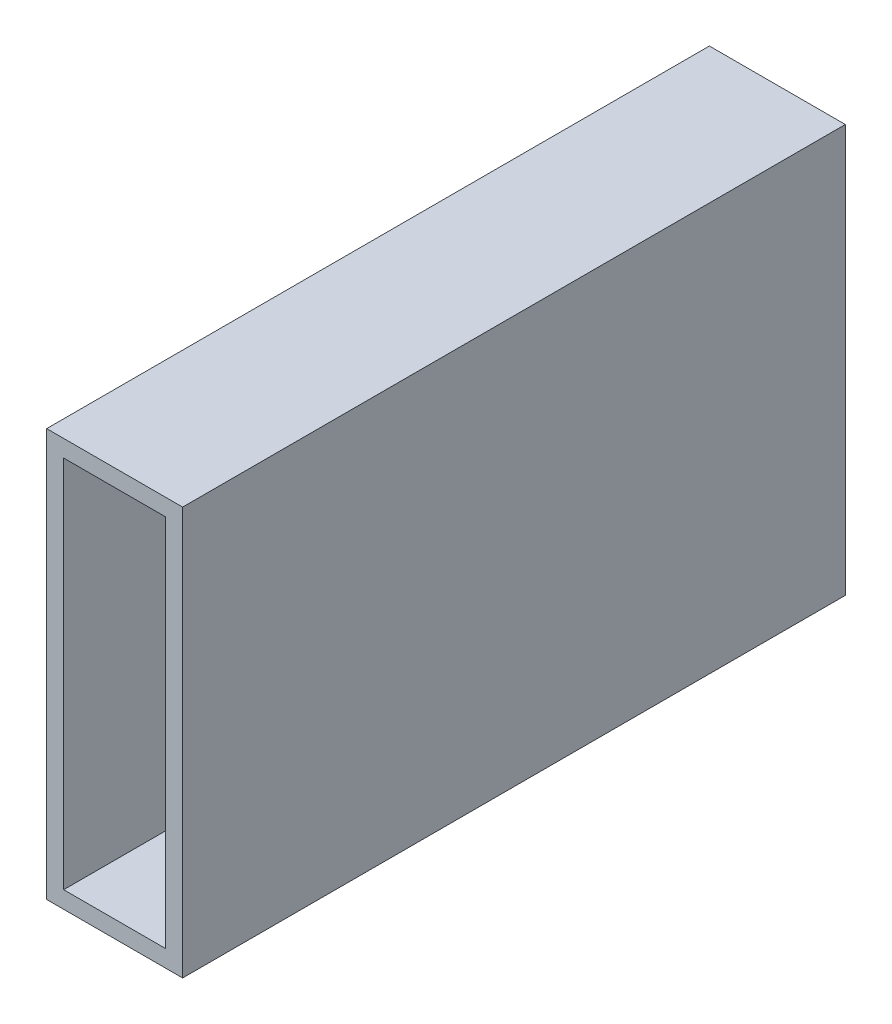
from build123d import *

# Parameters (mm, degrees)
SKETCH1_W           = 25.4
SKETCH1_H           = 76.2
BOSS_EXTRUDE1_DEPTH = 61.9125
SHELL1_T            = -3.175


with BuildPart() as part:
    # Sketch1 → Boss-Extrude1 (new body, symmetric)
    with BuildSketch(Plane.XY):
        Rectangle(SKETCH1_W, SKETCH1_H)
    extrude(amount=BOSS_EXTRUDE1_DEPTH, both=True)

    # Shell1
    shell1_openings = [part.faces().sort_by_distance(p)[0] for p in [
        (0, 0, 61.9125),
        (0, 0, -61.9125),
    ]]
    offset(amount=SHELL1_T, openings=shell1_openings, kind=Kind.INTERSECTION)


solid = part.part
